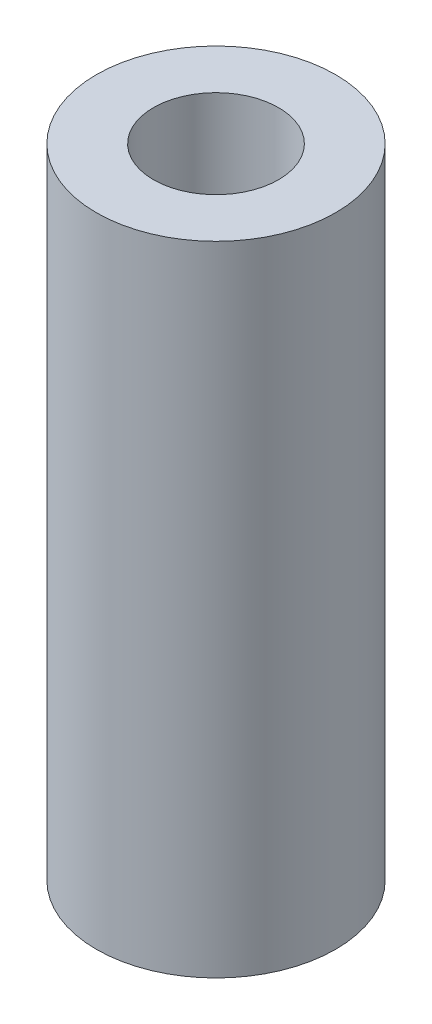
from build123d import *

# Parameters (mm, degrees)
SKETCH1_R           = 4.7625
SKETCH1_R_2         = 2.4892
BOSS_EXTRUDE1_DEPTH = 12.7


with BuildPart() as part:
    # Sketch1 → Boss-Extrude1 (new body, symmetric)
    with BuildSketch(Plane(origin=(0, 0, 0), x_dir=(1, 0, 0), z_dir=(0, 1, 0))):
        Circle(SKETCH1_R)
        Circle(SKETCH1_R_2, mode=Mode.SUBTRACT)
    extrude(amount=BOSS_EXTRUDE1_DEPTH, both=True)


solid = part.part
